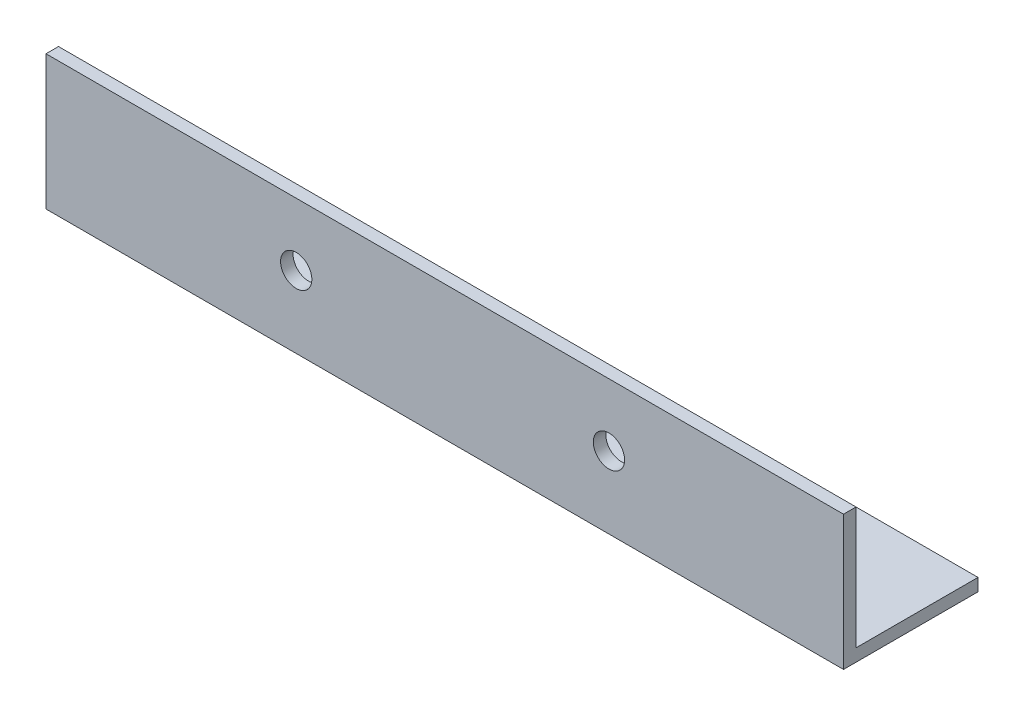
from build123d import *

# Parameters (mm, degrees)
EXTRUDE_1_DEPTH     = 255
SKETCH_2_R          = 5
CUT_EXTRUDE_1_DEPTH = 44


with BuildPart() as part:
    # Эскиз1 → Вытянуть-Тонкостенный1 (new body)
    with BuildSketch(Plane(origin=(0, 0, 0), x_dir=(0, 0, -1), z_dir=(1, 0, 0))):
        Polygon((0, 43), (0, 0), (43, 0), (43, 4), (4, 4), (4, 43), align=None)
    extrude(amount=EXTRUDE_1_DEPTH)

    # Эскиз2 → Вырез-Вытянуть1 (cut, through all)
    with BuildSketch(Plane.XY):
        with Locations((80, 23)):
            Circle(SKETCH_2_R)
        with Locations((180, 23)):
            Circle(SKETCH_2_R)
    extrude(amount=-CUT_EXTRUDE_1_DEPTH, mode=Mode.SUBTRACT)


solid = part.part
